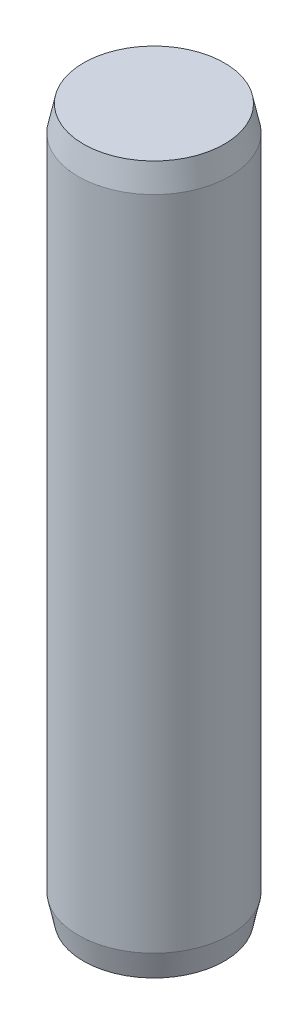
from build123d import *

# Parameters (mm, degrees)
SKETCH1_R           = 1.5
BOSS_EXTRUDE1_DEPTH = 14
CHAMFER1_SIZE       = 0.5
CHAMFER1_SIZE2      = 0.106278281
CHAMFER2_SIZE       = 0.5
CHAMFER2_SIZE2      = 0.106278281


with BuildPart() as part:
    # Sketch1 → Boss-Extrude1 (new body)
    with BuildSketch(Plane(origin=(0, 0, 0), x_dir=(1, 0, 0), z_dir=(0, 1, 0))):
        Circle(SKETCH1_R)
    extrude(amount=BOSS_EXTRUDE1_DEPTH)

    # Chamfer1
    chamfer1_edges = [part.edges().sort_by_distance(p)[0] for p in [
        (-1.5, 14, 0),
    ]]
    chamfer1_side = [part.faces().sort_by_distance(p)[0] for p in [
        (-1.5, 7, 0),
    ]]
    chamfer(chamfer1_edges, length=CHAMFER1_SIZE, length2=CHAMFER1_SIZE2, reference=chamfer1_side[0])

    # Chamfer2
    chamfer2_edges = [part.edges().sort_by_distance(p)[0] for p in [
        (-1.5, 0, 0),
    ]]
    chamfer2_side = [part.faces().sort_by_distance(p)[0] for p in [
        (-1.5, 6.75, 0),
    ]]
    chamfer(chamfer2_edges, length=CHAMFER2_SIZE, length2=CHAMFER2_SIZE2, reference=chamfer2_side[0])


solid = part.part
